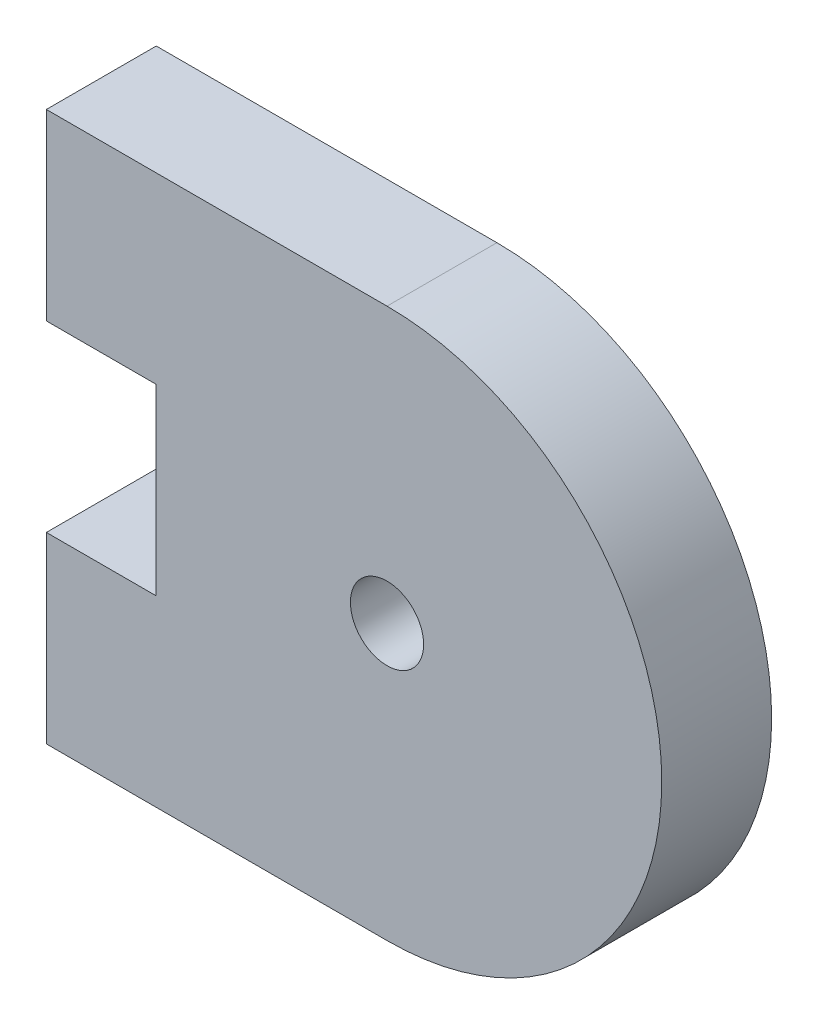
from build123d import *

# Parameters (mm, degrees)
CORTE_EXTERIOR_R        = 1
SALIENTE_EXTRUIR1_DEPTH = 3
GRABADO_SUPERFICIE_R    = 2.15
CORTAR_EXTRUIR1_DEPTH   = 1


with BuildPart() as part:
    # Corte exterior → Saliente-Extruir1 (new body)
    with BuildSketch(Plane.XY):
        with BuildLine():
            Line((42.4, 49.878566683), (33.1, 49.878566683))
            Line((33.1, 49.878566683), (33.1, 44.878566683))
            Line((33.1, 44.878566683), (36.1, 44.878566683))
            Line((36.1, 44.878566683), (36.1, 39.878566683))
            Line((36.1, 39.878566683), (33.1, 39.878566683))
            Line((33.1, 39.878566683), (33.1, 34.878566683))
            Line((33.1, 34.878566683), (42.4, 34.878566683))
            ThreePointArc((42.4, 34.878566683), (49.9, 42.378566683), (42.4, 49.878566683))
        make_face()
        with Locations((42.4, 42.378566683)):
            Circle(CORTE_EXTERIOR_R, mode=Mode.SUBTRACT)
    extrude(amount=SALIENTE_EXTRUIR1_DEPTH)

    # Grabado Superficie → Cortar-Extruir1 (cut)
    with BuildSketch(Plane.XY):
        with Locations((42.4, 42.378566683)):
            Circle(GRABADO_SUPERFICIE_R)
    extrude(amount=CORTAR_EXTRUIR1_DEPTH, mode=Mode.SUBTRACT)


solid = part.part
